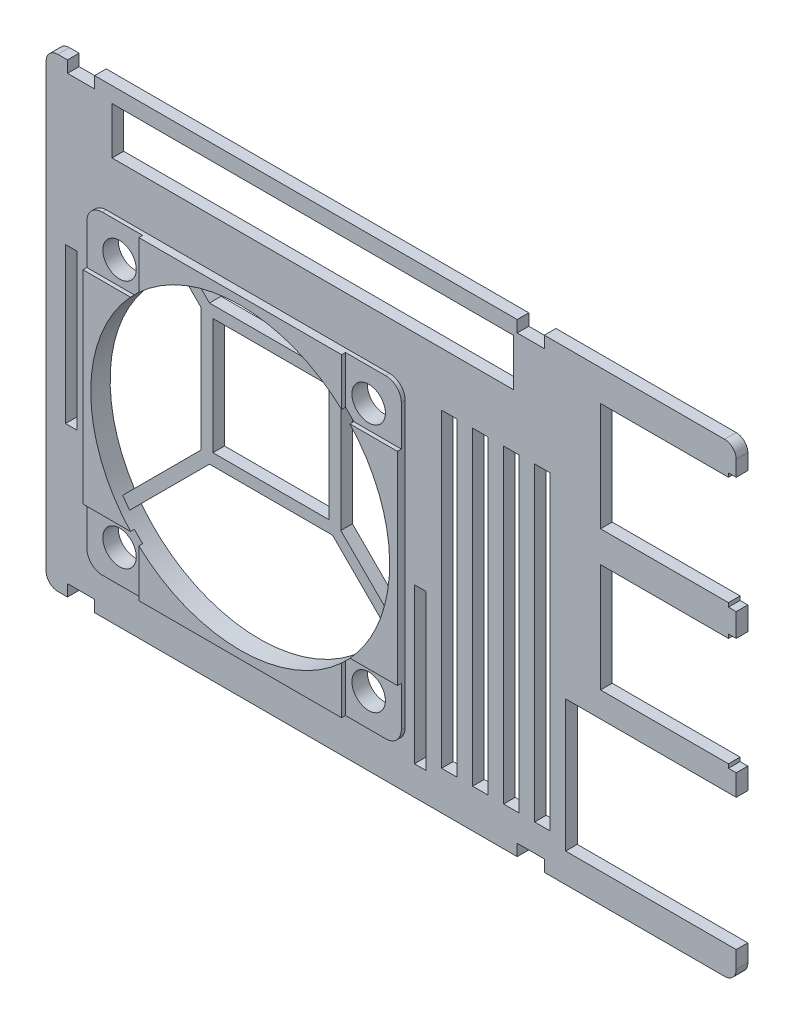
from build123d import *

# Parameters (mm, degrees)
BOSS_EXTRUDE1_DEPTH = 1.5
CUT_EXTRUDE1_REACH  = 3.5
SKETCH2_W           = 22
SKETCH2_H           = 17
SKETCH2_W_2         = 15
SKETCH2_H_2         = 15
SKETCH2_W_3         = 51.8
SKETCH2_H_3         = 6.08
SKETCH2_W_4         = 3.5
SKETCH2_H_4         = 1.5
SKETCH2_W_5         = 1.5
SKETCH2_H_5         = 20
SKETCH2_W_6         = 2
SKETCH2_H_6         = 40
SKETCH4_R           = 19.2779
BOSS_EXTRUDE2_DEPTH = 1
SKETCH5_R           = 2.159
CUT_EXTRUDE2_DEPTH  = 3.5
CUT_EXTRUDE3_START  = -0.5
SKETCH6_W           = 7.1929
SKETCH6_H           = 7.1929
CUT_EXTRUDE3_DEPTH  = 0.5


with BuildPart() as part:
    # Sketch1 → Boss-Extrude1 (new body)
    with BuildSketch(Plane.XY):
        with BuildLine():
            Line((-4, 54.5), (82, 54.5))
            ThreePointArc((82, 54.5), (83.060660172, 54.060660172), (83.5, 53))
            Line((83.5, 53), (83.5, -4))
            ThreePointArc((83.5, -4), (83.060660172, -5.060660172), (82, -5.5))
            Line((82, -5.5), (-4, -5.5))
            ThreePointArc((-4, -5.5), (-5.060660172, -5.060660172), (-5.5, -4))
            Line((-5.5, -4), (-5.5, 53))
            ThreePointArc((-5.5, 53), (-5.060660172, 54.060660172), (-4, 54.5))
        make_face()
    extrude(amount=BOSS_EXTRUDE1_DEPTH)

    # Sketch2 → Cut-Extrude1 (cut, up to next)
    with BuildSketch(Plane.XY.offset(1.5), mode=Mode.PRIVATE) as cut_extrude1_sk1:
        with Locations((72.5, 6.75)):
            Rectangle(SKETCH2_W, SKETCH2_H)
    cut_extrude1_tool1 = extrude(cut_extrude1_sk1.sketch, amount=-CUT_EXTRUDE1_REACH, mode=Mode.PRIVATE) & part.part
    add(cut_extrude1_tool1.solids().sort_by_distance((72.5, 6.75, 1.5))[0], mode=Mode.SUBTRACT)
    # Sketch2 → Cut-Extrude1 (cut, up to next)
    with BuildSketch(Plane.XY.offset(1.5), mode=Mode.PRIVATE) as cut_extrude1_sk2:
        with BuildLine():
            Line((14.5, 19.560660172), (14.5, 35.439339828))
            Line((14.5, 35.439339828), (12.459159923, 37.480179905))
            ThreePointArc((12.459159923, 37.480179905), (2.00356089, 25.309354814), (4.380533586, 9.441193757))
            Line((4.380533586, 9.441193757), (14.5, 19.560660172))
        make_face()
    cut_extrude1_tool2 = extrude(cut_extrude1_sk2.sketch, amount=-CUT_EXTRUDE1_REACH, mode=Mode.PRIVATE) & part.part
    add(cut_extrude1_tool2.solids().sort_by_distance((8.18014, 23.815992, 1.5))[0], mode=Mode.SUBTRACT)
    # Sketch2 → Cut-Extrude1 (cut, up to next)
    with BuildSketch(Plane.XY.offset(1.5), mode=Mode.PRIVATE) as cut_extrude1_sk3:
        Polygon((83.5, 18), (82.5, 18), (82.5, 18.5), (66, 18.5), (66, 32.5), (82.5, 32.5), (82.5, 33), (83.5, 33), align=None)
    cut_extrude1_tool3 = extrude(cut_extrude1_sk3.sketch, amount=-CUT_EXTRUDE1_REACH, mode=Mode.PRIVATE) & part.part
    add(cut_extrude1_tool3.solids().sort_by_distance((74.783537, 25.5, 1.5))[0], mode=Mode.SUBTRACT)
    # Sketch2 → Cut-Extrude1 (cut, up to next)
    with BuildSketch(Plane.XY.offset(1.5), mode=Mode.PRIVATE) as cut_extrude1_sk4:
        with BuildLine():
            Line((32.5, 35.081906418), (32.5, 19.560660172))
            Line((32.5, 19.560660172), (38.653532768, 13.407127404))
            ThreePointArc((38.653532768, 13.407127404), (39.072909862, 25.237082207), (32.5, 35.081906418))
        make_face()
    cut_extrude1_tool4 = extrude(cut_extrude1_sk4.sketch, amount=-CUT_EXTRUDE1_REACH, mode=Mode.PRIVATE) & part.part
    add(cut_extrude1_tool4.solids().sort_by_distance((35.862827, 23.7395, 1.5))[0], mode=Mode.SUBTRACT)
    # Sketch2 → Cut-Extrude1 (cut, up to next)
    with BuildSketch(Plane.XY.offset(1.5), mode=Mode.PRIVATE) as cut_extrude1_sk5:
        Polygon((66, 36.5), (82.5, 36.5), (82.5, 36), (83.5, 36), (83.5, 51), (82.5, 51), (82.5, 50.5), (66, 50.5), align=None)
    cut_extrude1_tool5 = extrude(cut_extrude1_sk5.sketch, amount=-CUT_EXTRUDE1_REACH, mode=Mode.PRIVATE) & part.part
    add(cut_extrude1_tool5.solids().sort_by_distance((74.783537, 43.5, 1.5))[0], mode=Mode.SUBTRACT)
    # Sketch2 → Cut-Extrude1 (cut, up to next)
    with BuildSketch(Plane.XY.offset(1.5), mode=Mode.PRIVATE) as cut_extrude1_sk6:
        with Locations((23.5, 27.5)):
            Rectangle(SKETCH2_W_2, SKETCH2_H_2)
    cut_extrude1_tool6 = extrude(cut_extrude1_sk6.sketch, amount=-CUT_EXTRUDE1_REACH, mode=Mode.PRIVATE) & part.part
    add(cut_extrude1_tool6.solids().sort_by_distance((23.5, 27.5, 1.5))[0], mode=Mode.SUBTRACT)
    # Sketch2 → Cut-Extrude1 (cut, up to next)
    with BuildSketch(Plane.XY.offset(1.5), mode=Mode.PRIVATE) as cut_extrude1_sk7:
        with Locations((28.9, 49.46)):
            Rectangle(SKETCH2_W_3, SKETCH2_H_3)
    cut_extrude1_tool7 = extrude(cut_extrude1_sk7.sketch, amount=-CUT_EXTRUDE1_REACH, mode=Mode.PRIVATE) & part.part
    add(cut_extrude1_tool7.solids().sort_by_distance((28.9, 49.46, 1.5))[0], mode=Mode.SUBTRACT)
    # Sketch2 → Cut-Extrude1 (cut, up to next)
    with BuildSketch(Plane.XY.offset(1.5), mode=Mode.PRIVATE) as cut_extrude1_sk8:
        with BuildLine():
            Line((15.560660172, 36.5), (30.450901058, 36.5))
            ThreePointArc((30.450901058, 36.5), (22.387275241, 39.160121058), (13.962927404, 38.097732768))
            Line((13.962927404, 38.097732768), (15.560660172, 36.5))
        make_face()
    cut_extrude1_tool8 = extrude(cut_extrude1_sk8.sketch, amount=-CUT_EXTRUDE1_REACH, mode=Mode.PRIVATE) & part.part
    add(cut_extrude1_tool8.solids().sort_by_distance((21.448512, 37.678321, 1.5))[0], mode=Mode.SUBTRACT)
    # Sketch2 → Cut-Extrude1 (cut, up to next)
    with BuildSketch(Plane.XY.offset(1.5), mode=Mode.PRIVATE) as cut_extrude1_sk9:
        with BuildLine():
            Line((5.26128006, 8.200619888), (15.560660172, 18.5))
            Line((15.560660172, 18.5), (31.439339828, 18.5))
            Line((31.439339828, 18.5), (38.035979905, 11.903359923))
            ThreePointArc((38.035979905, 11.903359923), (22.692064189, 0.816061219), (5.26128006, 8.200619888))
        make_face()
    cut_extrude1_tool9 = extrude(cut_extrude1_sk9.sketch, amount=-CUT_EXTRUDE1_REACH, mode=Mode.PRIVATE) & part.part
    add(cut_extrude1_tool9.solids().sort_by_distance((21.981845, 9.881453, 1.5))[0], mode=Mode.SUBTRACT)
    # Sketch2 → Cut-Extrude1 (cut, up to next)
    with BuildSketch(Plane.XY.offset(1.5), mode=Mode.PRIVATE) as cut_extrude1_sk10:
        with Locations((57, -4.75)):
            Rectangle(SKETCH2_W_4, SKETCH2_H_4)
    cut_extrude1_tool10 = extrude(cut_extrude1_sk10.sketch, amount=-CUT_EXTRUDE1_REACH, mode=Mode.PRIVATE) & part.part
    add(cut_extrude1_tool10.solids().sort_by_distance((57, -4.75, 1.5))[0], mode=Mode.SUBTRACT)
    # Sketch2 → Cut-Extrude1 (cut, up to next)
    with BuildSketch(Plane.XY.offset(1.5), mode=Mode.PRIVATE) as cut_extrude1_sk11:
        with Locations((-1, 53.75)):
            Rectangle(SKETCH2_W_4, SKETCH2_H_4)
    cut_extrude1_tool11 = extrude(cut_extrude1_sk11.sketch, amount=-CUT_EXTRUDE1_REACH, mode=Mode.PRIVATE) & part.part
    add(cut_extrude1_tool11.solids().sort_by_distance((-1, 53.75, 1.5))[0], mode=Mode.SUBTRACT)
    # Sketch2 → Cut-Extrude1 (cut, up to next)
    with BuildSketch(Plane.XY.offset(1.5), mode=Mode.PRIVATE) as cut_extrude1_sk12:
        with Locations((-1, -4.75)):
            Rectangle(SKETCH2_W_4, SKETCH2_H_4)
    cut_extrude1_tool12 = extrude(cut_extrude1_sk12.sketch, amount=-CUT_EXTRUDE1_REACH, mode=Mode.PRIVATE) & part.part
    add(cut_extrude1_tool12.solids().sort_by_distance((-1, -4.75, 1.5))[0], mode=Mode.SUBTRACT)
    # Sketch2 → Cut-Extrude1 (cut, up to next)
    with BuildSketch(Plane.XY.offset(1.5), mode=Mode.PRIVATE) as cut_extrude1_sk13:
        with Locations((57, 53.75)):
            Rectangle(SKETCH2_W_4, SKETCH2_H_4)
    cut_extrude1_tool13 = extrude(cut_extrude1_sk13.sketch, amount=-CUT_EXTRUDE1_REACH, mode=Mode.PRIVATE) & part.part
    add(cut_extrude1_tool13.solids().sort_by_distance((57, 53.75, 1.5))[0], mode=Mode.SUBTRACT)
    # Sketch2 → Cut-Extrude1 (cut, up to next)
    with BuildSketch(Plane.XY.offset(1.5), mode=Mode.PRIVATE) as cut_extrude1_sk14:
        with Locations((-2.25, 23.75)):
            Rectangle(SKETCH2_W_5, SKETCH2_H_5)
    cut_extrude1_tool14 = extrude(cut_extrude1_sk14.sketch, amount=-CUT_EXTRUDE1_REACH, mode=Mode.PRIVATE) & part.part
    add(cut_extrude1_tool14.solids().sort_by_distance((-2.25, 23.75, 1.5))[0], mode=Mode.SUBTRACT)
    # Sketch2 → Cut-Extrude1 (cut, up to next)
    with BuildSketch(Plane.XY.offset(1.5), mode=Mode.PRIVATE) as cut_extrude1_sk15:
        with Locations((42.75, 8.25)):
            Rectangle(SKETCH2_W_5, SKETCH2_H_5)
    cut_extrude1_tool15 = extrude(cut_extrude1_sk15.sketch, amount=-CUT_EXTRUDE1_REACH, mode=Mode.PRIVATE) & part.part
    add(cut_extrude1_tool15.solids().sort_by_distance((42.75, 8.25, 1.5))[0], mode=Mode.SUBTRACT)
    # Sketch2 → Cut-Extrude1 (cut, up to next)
    with BuildSketch(Plane.XY.offset(1.5), mode=Mode.PRIVATE) as cut_extrude1_sk16:
        with Locations((50.5, 19.5)):
            Rectangle(SKETCH2_W_6, SKETCH2_H_6)
    cut_extrude1_tool16 = extrude(cut_extrude1_sk16.sketch, amount=-CUT_EXTRUDE1_REACH, mode=Mode.PRIVATE) & part.part
    add(cut_extrude1_tool16.solids().sort_by_distance((50.5, 19.5, 1.5))[0], mode=Mode.SUBTRACT)
    # Sketch2 → Cut-Extrude1 (cut, up to next)
    with BuildSketch(Plane.XY.offset(1.5), mode=Mode.PRIVATE) as cut_extrude1_sk17:
        with Locations((46.5, 19.5)):
            Rectangle(SKETCH2_W_6, SKETCH2_H_6)
    cut_extrude1_tool17 = extrude(cut_extrude1_sk17.sketch, amount=-CUT_EXTRUDE1_REACH, mode=Mode.PRIVATE) & part.part
    add(cut_extrude1_tool17.solids().sort_by_distance((46.5, 19.5, 1.5))[0], mode=Mode.SUBTRACT)
    # Sketch2 → Cut-Extrude1 (cut, up to next)
    with BuildSketch(Plane.XY.offset(1.5), mode=Mode.PRIVATE) as cut_extrude1_sk18:
        with Locations((54.5, 19.5)):
            Rectangle(SKETCH2_W_6, SKETCH2_H_6)
    cut_extrude1_tool18 = extrude(cut_extrude1_sk18.sketch, amount=-CUT_EXTRUDE1_REACH, mode=Mode.PRIVATE) & part.part
    add(cut_extrude1_tool18.solids().sort_by_distance((54.5, 19.5, 1.5))[0], mode=Mode.SUBTRACT)
    # Sketch2 → Cut-Extrude1 (cut, up to next)
    with BuildSketch(Plane.XY.offset(1.5), mode=Mode.PRIVATE) as cut_extrude1_sk19:
        with Locations((58.5, 19.5)):
            Rectangle(SKETCH2_W_6, SKETCH2_H_6)
    cut_extrude1_tool19 = extrude(cut_extrude1_sk19.sketch, amount=-CUT_EXTRUDE1_REACH, mode=Mode.PRIVATE) & part.part
    add(cut_extrude1_tool19.solids().sort_by_distance((58.5, 19.5, 1.5))[0], mode=Mode.SUBTRACT)

    # Sketch4 → Boss-Extrude2 (add)
    with BuildSketch(Plane.XY.offset(1.5)):
        with BuildLine():
            Line((38.8058, 40.25), (2.25, 40.25))
            ThreePointArc((2.25, 40.25), (0.835786438, 39.664213562), (0.25, 38.25))
            Line((0.25, 38.25), (0.25, 1.6942))
            ThreePointArc((0.25, 1.6942), (0.835786438, 0.279986438), (2.25, -0.3058))
            Line((2.25, -0.3058), (38.8058, -0.3058))
            ThreePointArc((38.8058, -0.3058), (40.220013562, 0.279986438), (40.8058, 1.6942))
            Line((40.8058, 1.6942), (40.8058, 38.25))
            ThreePointArc((40.8058, 38.25), (40.220013562, 39.664213562), (38.8058, 40.25))
        make_face()
        with Locations((20.5279, 19.9721)):
            Circle(SKETCH4_R, mode=Mode.SUBTRACT)
    extrude(amount=BOSS_EXTRUDE2_DEPTH)

    # Sketch5 → Cut-Extrude2 (cut, through all)
    with BuildSketch(Plane.XY.offset(2.5)):
        with Locations((4.4624, 36.0376)):
            Circle(SKETCH5_R)
        with Locations((36.5934, 36.0376)):
            Circle(SKETCH5_R)
        with Locations((36.5934, 3.9066)):
            Circle(SKETCH5_R)
        with Locations((4.4624, 3.9066)):
            Circle(SKETCH5_R)
    extrude(amount=-CUT_EXTRUDE2_DEPTH, mode=Mode.SUBTRACT)

    # Sketch6 → Cut-Extrude3 (cut)
    with BuildSketch(Plane.XY.offset(2.5).offset(CUT_EXTRUDE3_START)):
        with Locations((37.20935, 3.29065)):
            Rectangle(SKETCH6_W, SKETCH6_H)
        with Locations((37.20935, 36.65355)):
            Rectangle(SKETCH6_W, SKETCH6_H)
        with Locations((3.84645, 3.29065)):
            Rectangle(SKETCH6_W, SKETCH6_H)
        with Locations((3.84645, 36.65355)):
            Rectangle(SKETCH6_W, SKETCH6_H)
    extrude(amount=CUT_EXTRUDE3_DEPTH, mode=Mode.SUBTRACT)


solid = part.part
